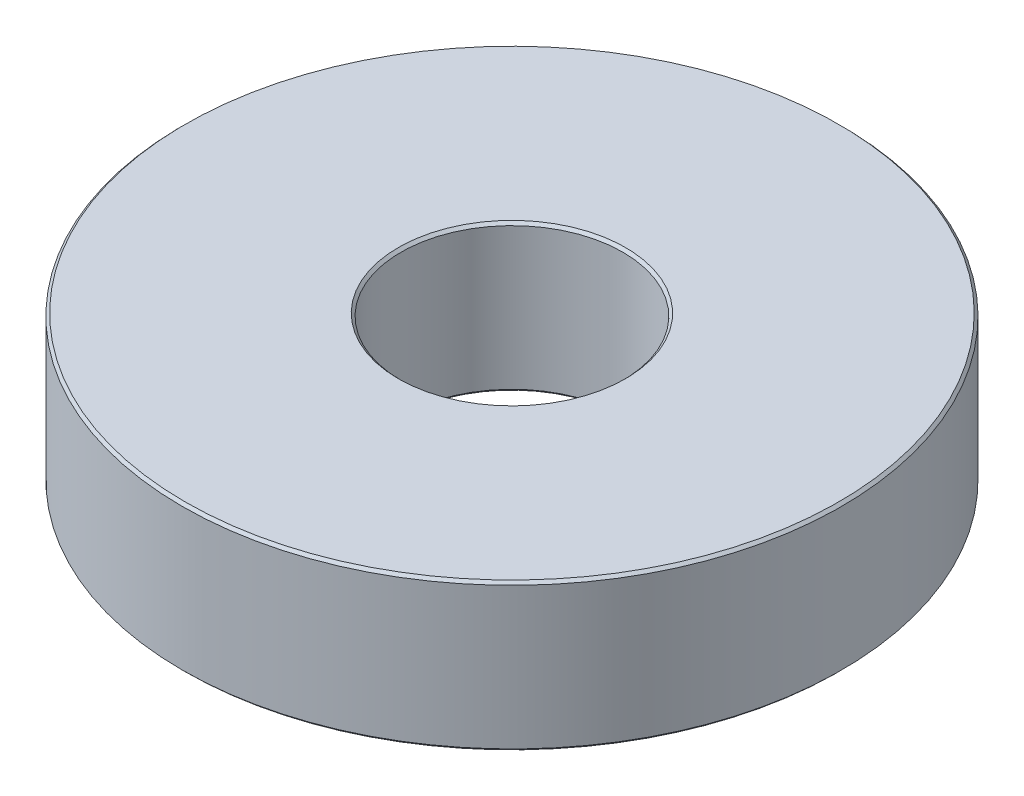
from build123d import *

# Parameters (mm, degrees)
SKETCH1_R           = 12.325
SKETCH1_R_2         = 4.15
BOSS_EXTRUDE1_DEPTH = 5.5
CHAMFER1_SIZE       = 0.1


with BuildPart() as part:
    # Sketch1 → Boss-Extrude1 (new body)
    with BuildSketch(Plane(origin=(0, 0, 0), x_dir=(1, 0, 0), z_dir=(0, 1, 0))):
        Circle(SKETCH1_R)
        Circle(SKETCH1_R_2, mode=Mode.SUBTRACT)
    extrude(amount=BOSS_EXTRUDE1_DEPTH)

    # Chamfer1
    chamfer1_edges = [part.edges().sort_by_distance(p)[0] for p in [
        (-12.325, 0, 0),
        (-12.325, 5.5, 0),
        (-4.15, 0, 0),
        (-4.15, 5.5, 0),
    ]]
    chamfer(chamfer1_edges, length=CHAMFER1_SIZE)


solid = part.part
